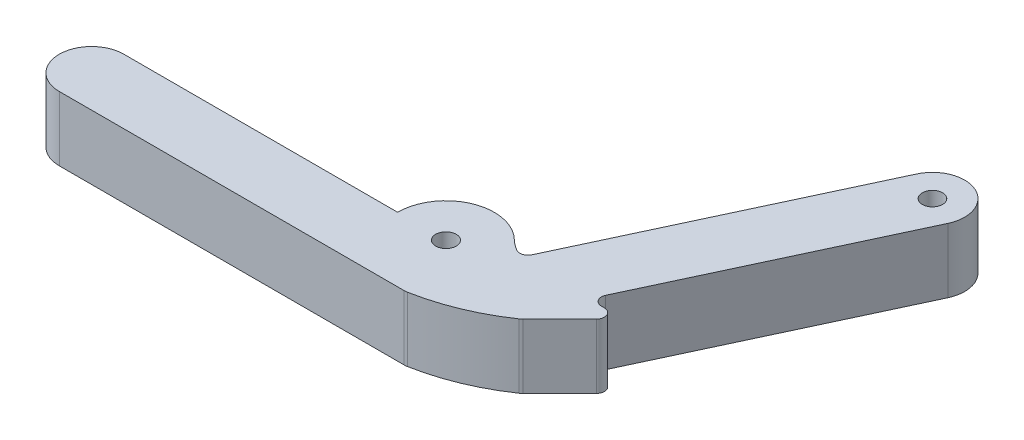
from build123d import *

# Parameters (mm, degrees)
SKETCH1_R           = 4.05
SKETCH1_R_2         = 4
BOSS_EXTRUDE1_DEPTH = 25.4


with BuildPart() as part:
    # Sketch1 → Boss-Extrude1 (new body)
    with BuildSketch(Plane(origin=(0, 0, 0), x_dir=(1, 0, 0), z_dir=(0, 1, 0))):
        with BuildLine():
            Line((35.095585876, 75.150873895), (-72.841125884, 75.150873895))
            ThreePointArc((-72.841125884, 75.150873895), (-85.568525883, 62.423473896), (-72.841125884, 49.696073896))
            Line((-72.841125884, 49.696073896), (38.270585876, 49.696073896))
            Line((38.270585876, 49.696073896), (63.158100717, 49.696073896))
            ThreePointArc((63.158100717, 49.696073896), (63.742381743, 49.723011689), (64.321705528, 49.803596516))
            ThreePointArc((64.321705528, 49.803596516), (80.546596989, 54.618688797), (95.424112169, 62.686635169))
            ThreePointArc((95.424112169, 62.686635169), (95.890738024, 63.039296868), (96.322934996, 63.433398048))
            Line((96.322934996, 63.433398048), (110.746065504, 77.856528557))
            ThreePointArc((110.746065504, 77.856528557), (111.43431899, 81.316612485), (108.501001474, 83.276592587))
            Line((108.501001474, 83.276592587), (107.323802413, 83.276592587))
            ThreePointArc((107.323802413, 83.276592587), (104.646034573, 84.74566633), (104.44627519, 87.793405568))
            Line((104.44627519, 87.793405568), (147.384290582, 179.874276731))
            ThreePointArc((147.384290582, 179.874276731), (141.241433611, 196.75163755), (124.364072791, 190.608780579))
            Line((124.364072791, 190.608780579), (76.090158478, 87.085037255))
            ThreePointArc((76.090158478, 87.085037255), (74.19673791, 85.408214933), (71.67884134, 85.646901766))
            ThreePointArc((71.67884134, 85.646901766), (69.496098635, 87.053305606), (67.524885923, 88.743470663))
            ThreePointArc((67.524885923, 88.743470663), (46.789721423, 92.732243213), (35.095585876, 75.150873895))
        make_face()
        with Locations((54.158874116, 75.150873895)):
            Circle(SKETCH1_R, mode=Mode.SUBTRACT)
        with Locations((135.874181687, 185.241528655)):
            Circle(SKETCH1_R_2, mode=Mode.SUBTRACT)
    extrude(amount=BOSS_EXTRUDE1_DEPTH)


solid = part.part
